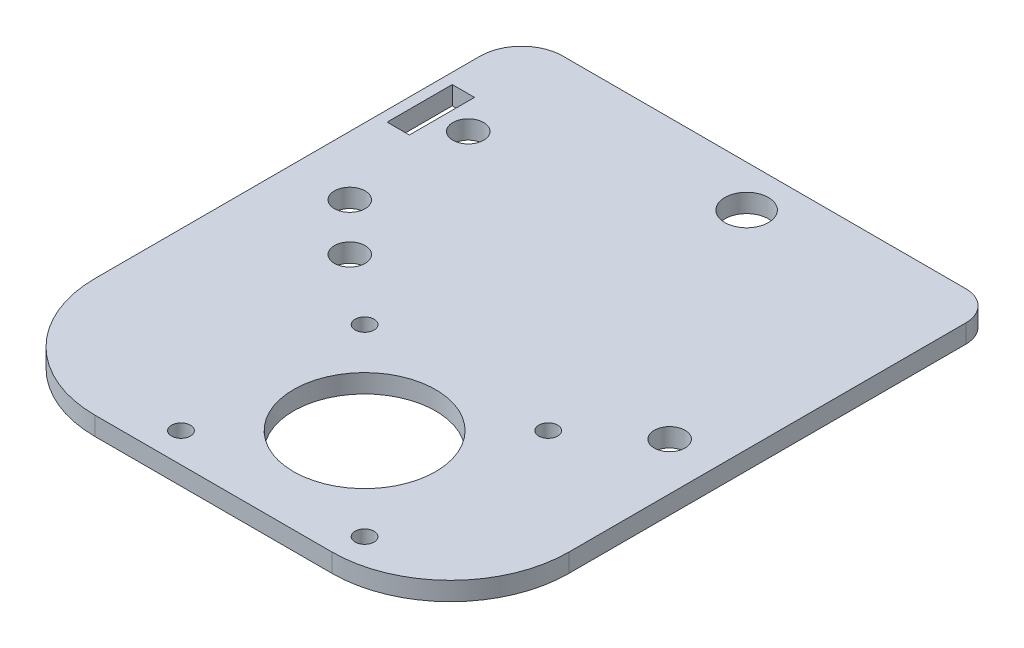
from build123d import *

# Parameters (mm, degrees)
SKETCH2_W           = 80
SKETCH2_H           = 92
SKETCH2_R           = 1.6
SKETCH2_R_2         = 2.6
SKETCH2_R_3         = 12
SKETCH2_R_4         = 3.675
SKETCH2_W_2         = 3.760660172
SKETCH2_H_2         = 11
BOSS_EXTRUDE1_DEPTH = 3.125
FILLET1_R           = 20
FILLET2_R           = 20
FILLET4_R           = 5
FILLET5_R           = 7


with BuildPart() as part:
    # Sketch2 → Boss-Extrude1 (new body)
    with BuildSketch(Plane(origin=(0, 0, 0), x_dir=(1, 0, 0), z_dir=(0, 1, 0))):
        with Locations((40, 46)):
            Rectangle(SKETCH2_W, SKETCH2_H)
        with Locations((29.5, 5)):
            Circle(SKETCH2_R, mode=Mode.SUBTRACT)
        with Locations((29.5, 36)):
            Circle(SKETCH2_R, mode=Mode.SUBTRACT)
        with Locations((60.5, 36)):
            Circle(SKETCH2_R, mode=Mode.SUBTRACT)
        with Locations((60.5, 5)):
            Circle(SKETCH2_R, mode=Mode.SUBTRACT)
        with Locations((18, 45)):
            Circle(SKETCH2_R_2, mode=Mode.SUBTRACT)
        with Locations((72, 45)):
            Circle(SKETCH2_R_2, mode=Mode.SUBTRACT)
        with Locations((45, 20.5)):
            Circle(SKETCH2_R_3, mode=Mode.SUBTRACT)
        with Locations((45, 85)):
            Circle(SKETCH2_R_4, mode=Mode.SUBTRACT)
        with Locations((10, 53)):
            Circle(SKETCH2_R_2, mode=Mode.SUBTRACT)
        with Locations((10, 73)):
            Circle(SKETCH2_R_2, mode=Mode.SUBTRACT)
        with Locations((3.680330086, 73)):
            Rectangle(SKETCH2_W_2, SKETCH2_H_2, mode=Mode.SUBTRACT)
    extrude(amount=BOSS_EXTRUDE1_DEPTH)

    # Fillet1
    fillet1_edges = [part.edges().sort_by_distance(p)[0] for p in [
        (80, 1.5625, 0),
    ]]
    fillet(fillet1_edges, radius=FILLET1_R)

    # Fillet2
    fillet2_edges = [part.edges().sort_by_distance(p)[0] for p in [
        (0, 1.5625, 0),
    ]]
    fillet(fillet2_edges, radius=FILLET2_R)

    # Fillet4
    fillet4_edges = [part.edges().sort_by_distance(p)[0] for p in [
        (80, 1.5625, -92),
    ]]
    fillet(fillet4_edges, radius=FILLET4_R)

    # Fillet5
    fillet5_edges = [part.edges().sort_by_distance(p)[0] for p in [
        (0, 1.5625, -92),
    ]]
    fillet(fillet5_edges, radius=FILLET5_R)


solid = part.part
